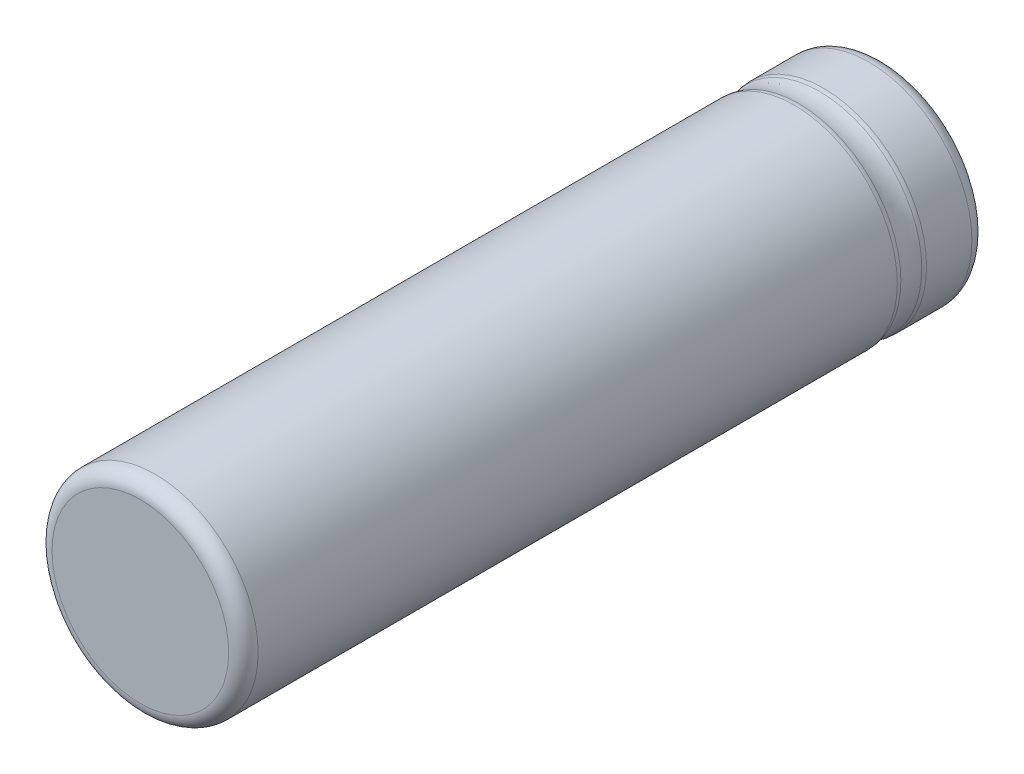
from build123d import *

# Parameters (mm, degrees)
SKETCH1_R      = 7
EXTRUDE1_DEPTH = 50.5
SKETCH2_R      = 2.5
FILLET1_R      = 1


with BuildPart() as part:
    # Sketch1 → Extrude1 (new body)
    with BuildSketch(Plane.XY):
        Circle(SKETCH1_R)
    extrude(amount=EXTRUDE1_DEPTH)

    # Sketch2 → Cut-Revolve1 (revolve, cut)
    with BuildSketch(Plane(origin=(0, 0, 0), x_dir=(0, 0, -1), z_dir=(1, 0, 0)), mode=Mode.PRIVATE) as cut_revolve1_sk:
        with Locations((-5.077096521, 9.355816897)):
            Circle(SKETCH2_R)
    revolve(cut_revolve1_sk.sketch.rotate(Axis((0, 0, 0), (0, 0, 1)), 90), axis=Axis((0, 0, 0), (0, 0, 1)), mode=Mode.SUBTRACT)  # turned: the seam where the file's is

    # Fillet1
    fillet1_edges = [part.edges().sort_by_distance(p)[0] for p in [
        (-7, 0, 0),
        (-7, 0, 50.5),
        (0, 7, 5.913832289),
        (0, -7, 4.240360753),
    ]]
    fillet(fillet1_edges, radius=FILLET1_R)


solid = part.part
